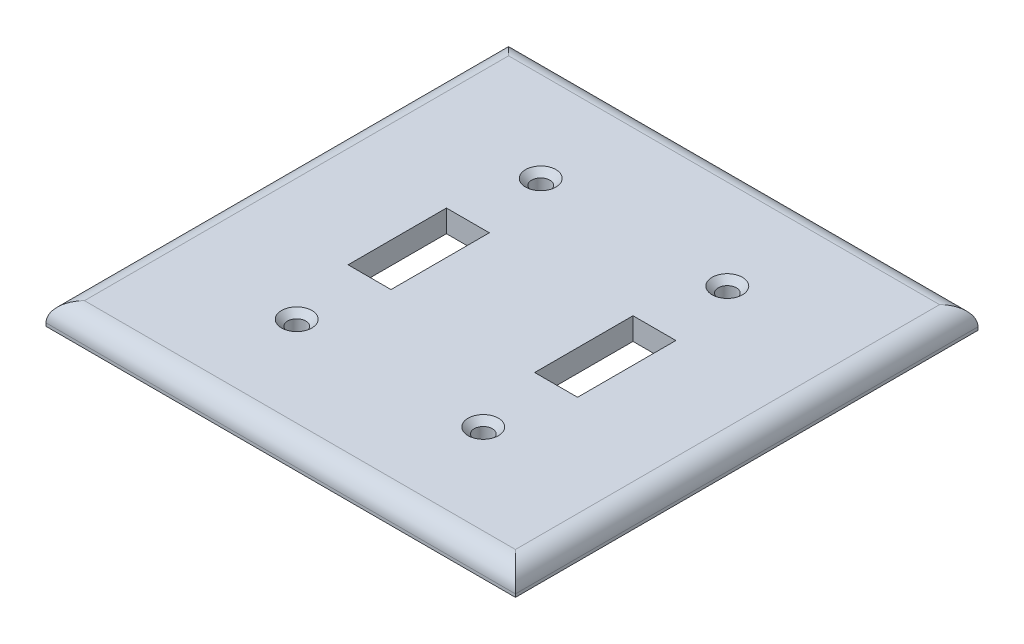
from build123d import *

# Parameters (mm, degrees)
SKETCH1_W           = 116
SKETCH1_H           = 114.3
SKETCH1_R           = 2.25
SKETCH1_W_2         = 10.6
SKETCH1_H_2         = 24.3
BOSS_EXTRUDE1_DEPTH = 5.5
FILLET1_R           = 4.75
CHAMFER1_SIZE       = 1.5


with BuildPart() as part:
    # Sketch1 → Boss-Extrude1 (new body)
    with BuildSketch(Plane(origin=(0, 0, 0), x_dir=(1, 0, 0), z_dir=(0, 1, 0))):
        with Locations((-3.024594732, -5.827064496)):
            Rectangle(SKETCH1_W, SKETCH1_H)
        with Locations((-26.074594732, 24.322935504)):
            Circle(SKETCH1_R, mode=Mode.SUBTRACT)
        with Locations((-26.074594732, -35.977064496)):
            Circle(SKETCH1_R, mode=Mode.SUBTRACT)
        with Locations((20.025405268, -35.977064496)):
            Circle(SKETCH1_R, mode=Mode.SUBTRACT)
        with Locations((20.025405268, 24.322935504)):
            Circle(SKETCH1_R, mode=Mode.SUBTRACT)
        with Locations((-26.074594732, -5.827064496)):
            Rectangle(SKETCH1_W_2, SKETCH1_H_2, mode=Mode.SUBTRACT)
        with Locations((20.025405268, -5.827064496)):
            Rectangle(SKETCH1_W_2, SKETCH1_H_2, mode=Mode.SUBTRACT)
    extrude(amount=BOSS_EXTRUDE1_DEPTH)

    # Fillet1
    fillet1_edges = [part.edges().sort_by_distance(p)[0] for p in [
        (54.975405268, 5.5, 5.827064496),
        (-3.024594732, 5.5, -51.322935504),
        (-61.024594732, 5.5, 5.827064496),
        (-3.024594732, 5.5, 62.977064496),
    ]]
    fillet(fillet1_edges, radius=FILLET1_R)

    # Chamfer1
    chamfer1_edges = [part.edges().sort_by_distance(p)[0] for p in [
        (17.775405268, 5.5, 35.977064496),
        (-28.324594732, 5.5, 35.977064496),
        (-28.324594732, 5.5, -24.322935504),
        (17.775405268, 5.5, -24.322935504),
    ]]
    chamfer(chamfer1_edges, length=CHAMFER1_SIZE)


solid = part.part
